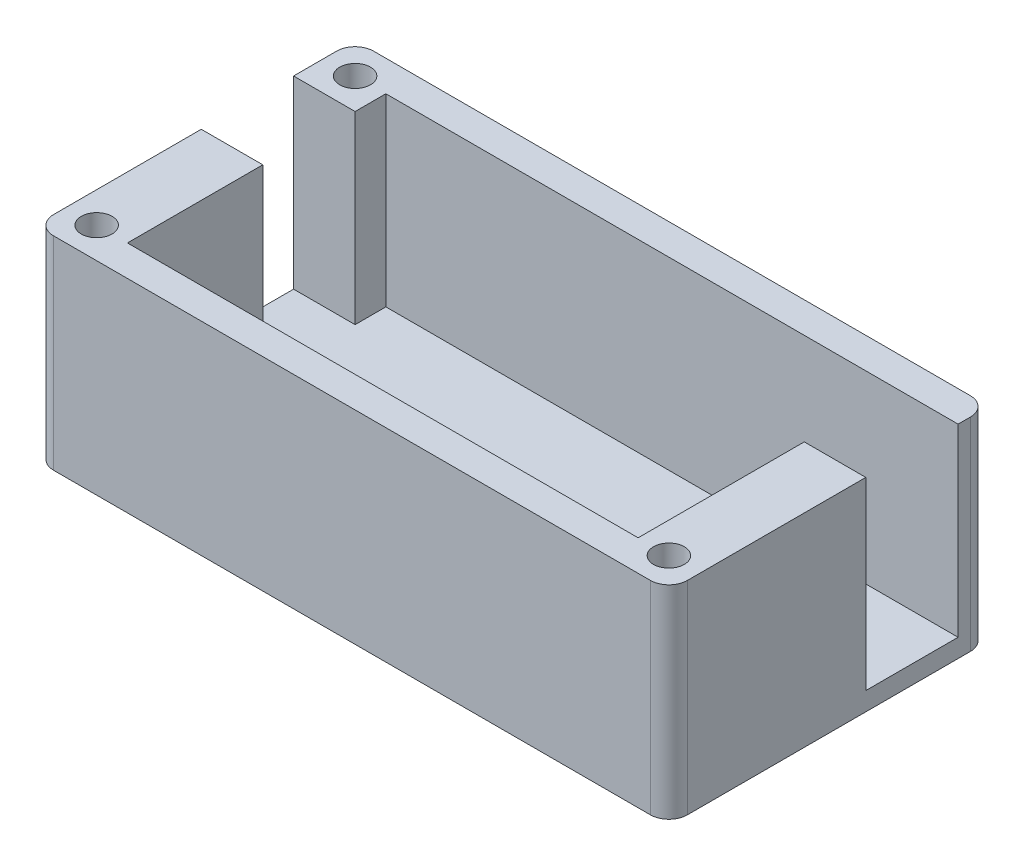
from build123d import *

# Parameters (mm, degrees)
SKETCH1_W                 = 103
SKETCH1_H                 = 52
SKETCH1_W_2               = 83
SKETCH1_H_2               = 42
BOSS_EXTRUDE1_DEPTH       = 30
SKETCH2_W                 = 103
SKETCH2_H                 = 52
BOSS_EXTRUDE2_DEPTH       = 3
SKETCH3_W                 = 10
SKETCH3_H                 = 15
CUT_EXTRUDE1_DEPTH        = 30
F_5_0MM_DOWEL_HOLE1_D     = 5
F_5_0MM_DOWEL_HOLE1_DEPTH = 10
F_5_0MM_DOWEL_HOLE1_TIP   = 1.502151548
FILLET1_R                 = 3


with BuildPart() as part:
    # Sketch1 → Boss-Extrude1 (new body)
    with BuildSketch(Plane(origin=(0, 0, 0), x_dir=(1, 0, 0), z_dir=(0, 1, 0))):
        Rectangle(SKETCH1_W, SKETCH1_H)
        Rectangle(SKETCH1_W_2, SKETCH1_H_2, mode=Mode.SUBTRACT)
    extrude(amount=BOSS_EXTRUDE1_DEPTH)

    # Sketch2 → Boss-Extrude2 (add)
    with BuildSketch(Plane.XZ):
        Rectangle(SKETCH2_W, SKETCH2_H)
    extrude(amount=BOSS_EXTRUDE2_DEPTH)

    # Sketch3 → Cut-Extrude1 (cut)
    with BuildSketch(Plane(origin=(0, 30, 0), x_dir=(1, 0, 0), z_dir=(0, 1, 0))):
        with Locations((46.5, 13.5)):
            Rectangle(SKETCH3_W, SKETCH3_H)
        with Locations((-46.5, 8.5)):
            Rectangle(SKETCH3_W, SKETCH3_H)
    extrude(amount=-CUT_EXTRUDE1_DEPTH, mode=Mode.SUBTRACT)

    # Ø5.0mm Dowel Hole1
    with Locations(Plane(origin=(0, 30, 0), x_dir=(1, 0, 0), z_dir=(0, 1, 0))):
        with Locations((-46.5, 21), (46.5, -21), (-46.5, -21)):
            Hole(F_5_0MM_DOWEL_HOLE1_D / 2, depth=F_5_0MM_DOWEL_HOLE1_DEPTH)
            with Locations((0, 0, -(F_5_0MM_DOWEL_HOLE1_DEPTH + F_5_0MM_DOWEL_HOLE1_TIP / 2))):  # 118° drill point
                Cone(0, F_5_0MM_DOWEL_HOLE1_D / 2, F_5_0MM_DOWEL_HOLE1_TIP, mode=Mode.SUBTRACT)

    # Fillet1
    fillet1_edges = [part.edges().sort_by_distance(p)[0] for p in [
        (51.5, 13.5, 26),
        (-51.5, 13.5, 26),
        (-51.5, 13.5, -26),
        (51.5, 13.5, -26),
    ]]
    fillet(fillet1_edges, radius=FILLET1_R)


solid = part.part
